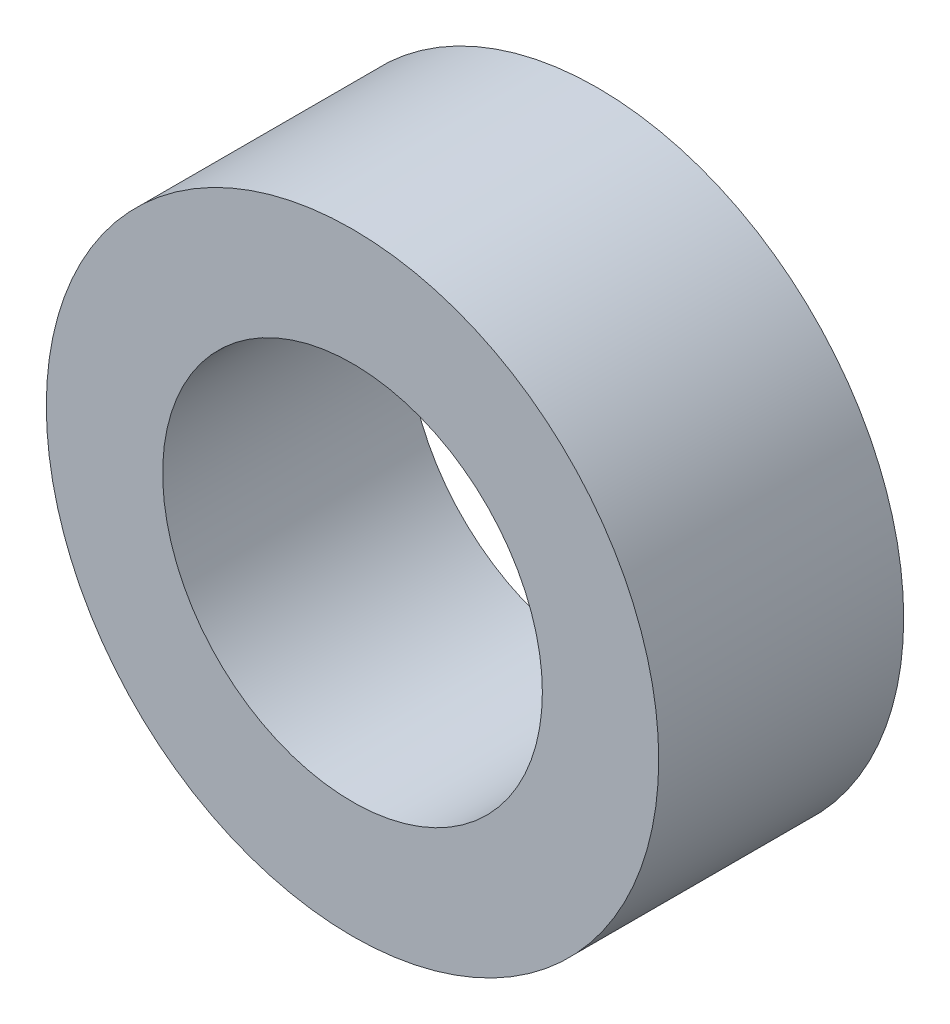
from build123d import *

# Parameters (mm, degrees)
SKETCH_1_R      = 5
SKETCH_1_R_2    = 3.1
EXTRUDE_1_DEPTH = 4


with BuildPart() as part:
    # ｽｹｯﾁ1 → ﾎﾞｽ - 押し出し1 (new body)
    with BuildSketch(Plane.XY):
        Circle(SKETCH_1_R)
        Circle(SKETCH_1_R_2, mode=Mode.SUBTRACT)
    extrude(amount=EXTRUDE_1_DEPTH)


solid = part.part
